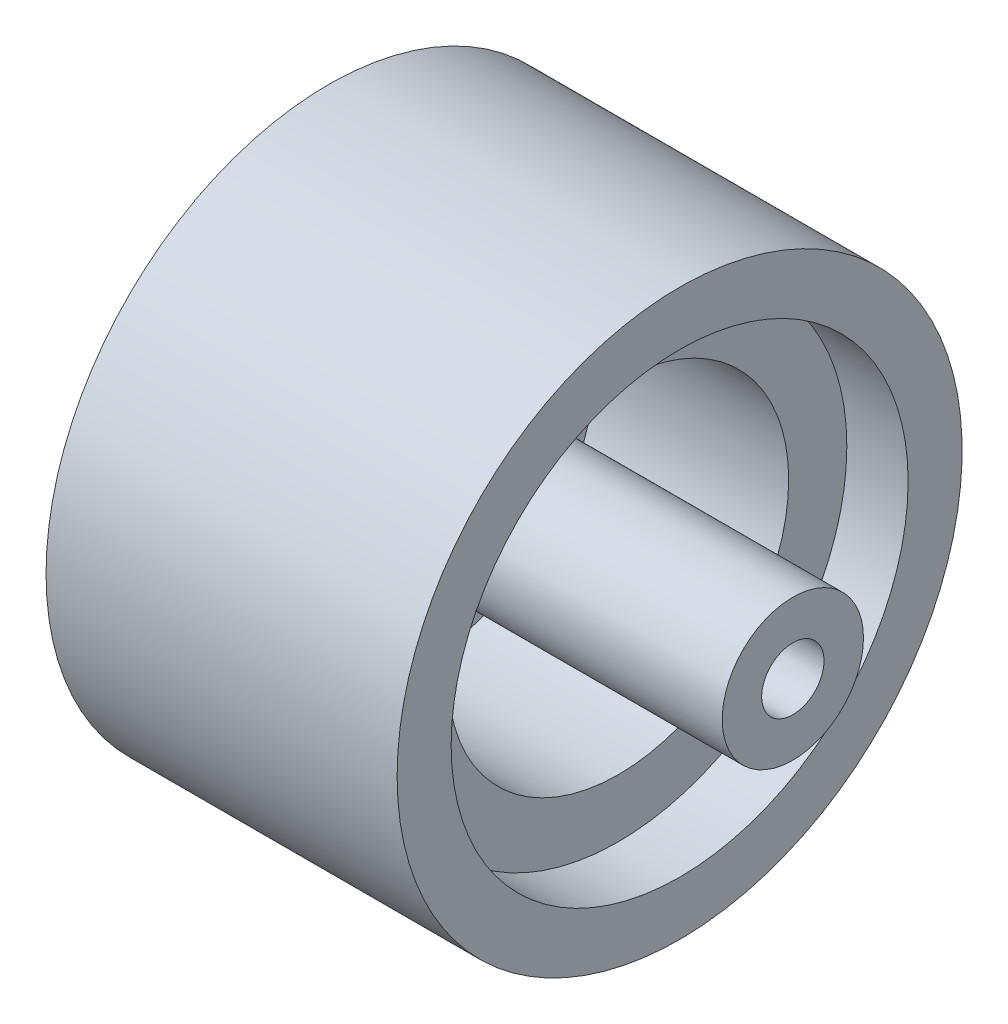
from build123d import *

# Parameters (mm, degrees)
SKETCH_1_R           = 11
EXTRUDE_1_DEPTH      = 11
SKETCH_2_R           = 8.2
CUT_EXTRUDE_1_DEPTH  = 9.35
SKETCH_4_R           = 3.4
EXTRUDE_2_DEPTH      = 17.75
SKETCH_5_R           = 1.5
CUT_EXTRUDE_4_DEPTH  = 25.75
SKETCH_6_R           = 13.6
SKETCH_6_R_2         = 11
EXTRUDE_4_DEPTH      = 2.95
EXTRUDE_4_DEPTH_BACK = 13.95


with BuildPart() as part:
    # ｽｹｯﾁ1 → ﾎﾞｽ - 押し出し1 (new body)
    with BuildSketch(Plane(origin=(0, 0, 0), x_dir=(0, 0, -1), z_dir=(1, 0, 0))):
        Circle(SKETCH_1_R)
    extrude(amount=EXTRUDE_1_DEPTH)

    # ｽｹｯﾁ2 → ｶｯﾄ - 押し出し1 (cut)
    with BuildSketch(Plane(origin=(11, 0, 0), x_dir=(0, 0, -1), z_dir=(1, 0, 0))):
        Circle(SKETCH_2_R)
    extrude(amount=-CUT_EXTRUDE_1_DEPTH, mode=Mode.SUBTRACT)

    # ｽｹｯﾁ4 → ﾎﾞｽ - 押し出し2 (add)
    with BuildSketch(Plane(origin=(1.65, 0, 0), x_dir=(0, 0, -1), z_dir=(1, 0, 0))):
        Circle(SKETCH_4_R)
    extrude(amount=EXTRUDE_2_DEPTH)

    # ｽｹｯﾁ5 → ｶｯﾄ - 押し出し4 (cut)
    with BuildSketch(Plane(origin=(19.4, 0, 0), x_dir=(0, 0, -1), z_dir=(1, 0, 0))):
        Circle(SKETCH_5_R)
    extrude(amount=-CUT_EXTRUDE_4_DEPTH, mode=Mode.SUBTRACT)

    # ｽｹｯﾁ6 → ﾎﾞｽ - 押し出し4 (add, two sides)
    with BuildSketch(Plane.ZY) as extrude_4_sk:
        Circle(SKETCH_6_R)
        Circle(SKETCH_6_R_2, mode=Mode.SUBTRACT)
    extrude(amount=EXTRUDE_4_DEPTH)
    extrude(extrude_4_sk.sketch, amount=-EXTRUDE_4_DEPTH_BACK)


solid = part.part
